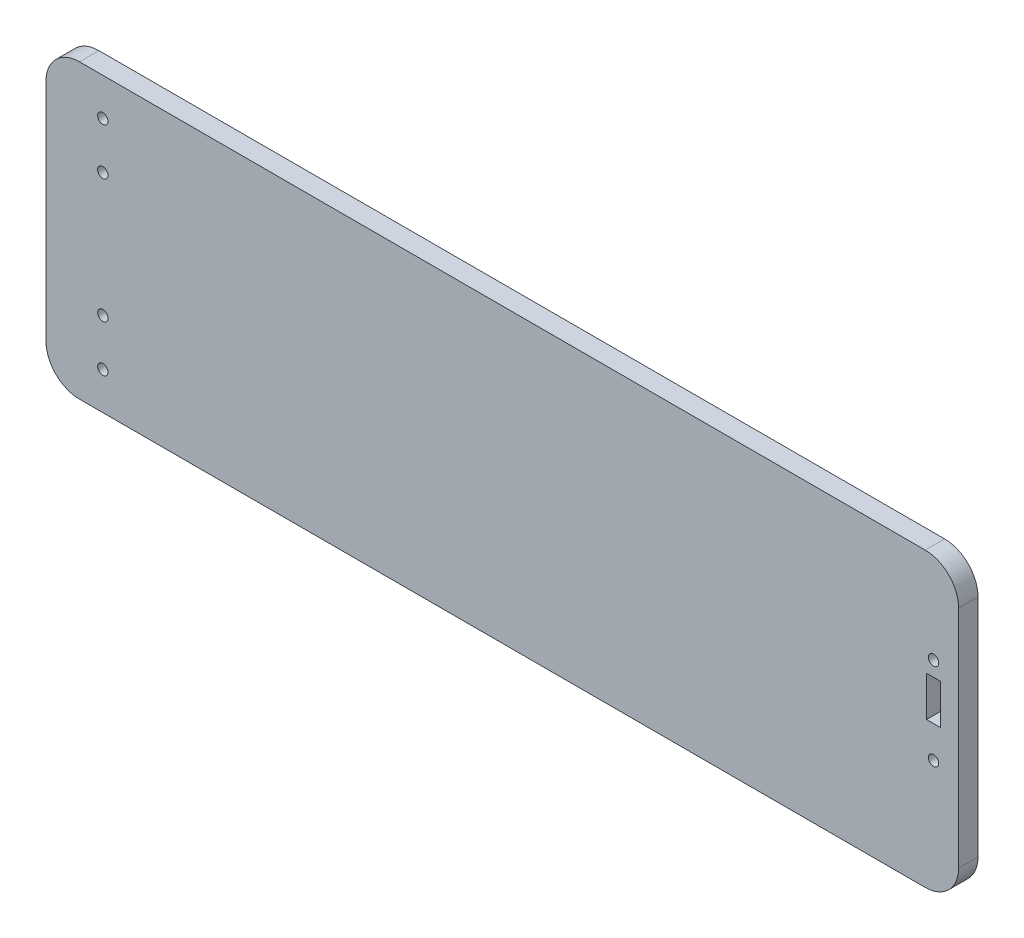
from build123d import *

# Parameters (mm, degrees)
BOSS_EXTRUDE1_DEPTH = 5.8
SKETCH3_W           = 4.2
SKETCH3_H           = 12
CUT_EXTRUDE1_DEPTH  = 6.35
SKETCH4_R           = 1.55
CUT_EXTRUDE2_DEPTH  = 6.8
SKETCH5_R           = 1.55
CUT_EXTRUDE3_DEPTH  = 6.8


with BuildPart() as part:
    # Sketch2 → Boss-Extrude1 (new body)
    with BuildSketch(Plane.XY):
        with BuildLine():
            Line((263, 43.7), (10, 43.7))
            ThreePointArc((10, 43.7), (2.928932188, 40.771067812), (0, 33.7))
            Line((0, 33.7), (0, -33.7))
            ThreePointArc((0, -33.7), (2.928932188, -40.771067812), (10, -43.7))
            Line((10, -43.7), (263, -43.7))
            ThreePointArc((263, -43.7), (270.071067812, -40.771067812), (273, -33.7))
            Line((273, -33.7), (273, 33.7))
            ThreePointArc((273, 33.7), (270.071067812, 40.771067812), (263, 43.7))
        make_face()
    extrude(amount=BOSS_EXTRUDE1_DEPTH)

    # Sketch3 → Cut-Extrude1 (cut)
    with BuildSketch(Plane.XY.offset(5.8)):
        with Locations((265.5, 6)):
            Rectangle(SKETCH3_W, SKETCH3_H)
    extrude(amount=-CUT_EXTRUDE1_DEPTH, mode=Mode.SUBTRACT)

    # Sketch4 → Cut-Extrude2 (cut, through all)
    with BuildSketch(Plane.XY.offset(5.8)):
        with Locations((17, 32.5)):
            Circle(SKETCH4_R)
        with Locations((17, 18.5)):
            Circle(SKETCH4_R)
        with Locations((17, -18.5)):
            Circle(SKETCH4_R)
        with Locations((17, -32.5)):
            Circle(SKETCH4_R)
    extrude(amount=-CUT_EXTRUDE2_DEPTH, mode=Mode.SUBTRACT)

    # Sketch5 → Cut-Extrude3 (cut, through all)
    with BuildSketch(Plane.XY.offset(5.8)):
        with Locations((265.5, 16.45)):
            Circle(SKETCH5_R)
        with Locations((265.5, -9.55)):
            Circle(SKETCH5_R)
    extrude(amount=-CUT_EXTRUDE3_DEPTH, mode=Mode.SUBTRACT)


solid = part.part
